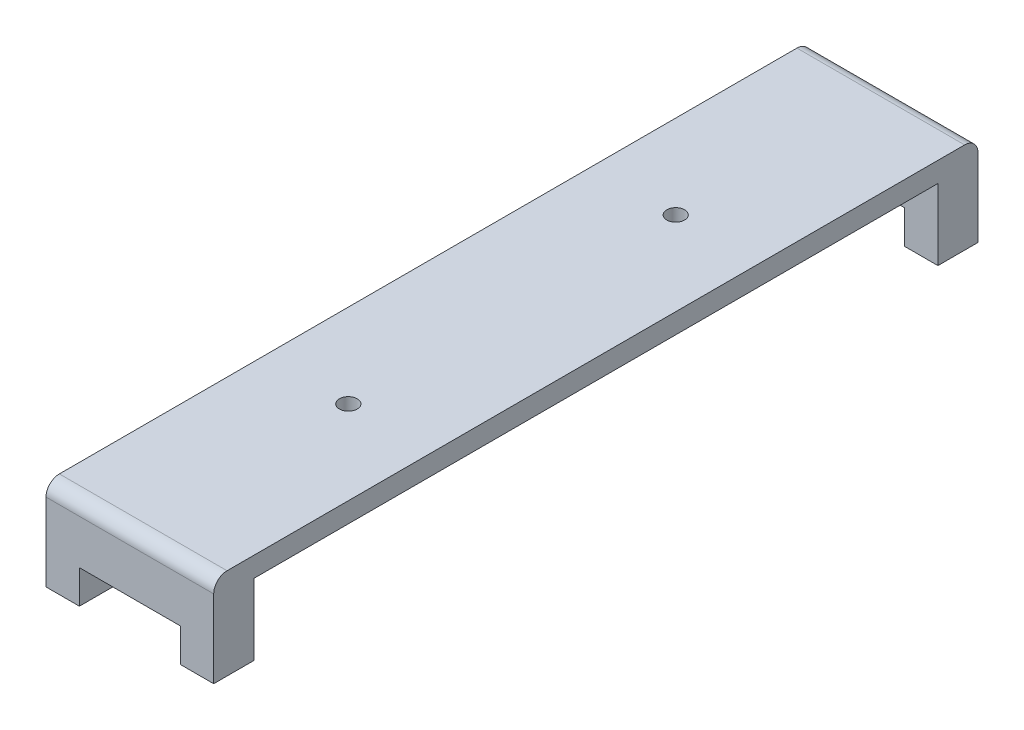
from build123d import *

# Parameters (mm, degrees)
SKETCH2_W           = 25.1
SKETCH2_H           = 57.2
SKETCH2_R           = 1.335
BOSS_EXTRUDE1_DEPTH = 3
BOSS_EXTRUDE2_DEPTH = 6
FILLET1_R           = 2


with BuildPart() as part:
    # Sketch2 → Boss-Extrude1 (new body)
    with BuildSketch(Plane(origin=(0, 0, 0), x_dir=(1, 0, 0), z_dir=(0, 1, 0))):
        with Locations((0, 28.6)):
            Rectangle(SKETCH2_W, SKETCH2_H)
        with Locations((0, 24.5)):
            Circle(SKETCH2_R, mode=Mode.SUBTRACT)
    boss_extrude1 = extrude(amount=BOSS_EXTRUDE1_DEPTH)

    # Sketch4 → Boss-Extrude2 (add)
    with BuildSketch(Plane(origin=(0, 0, -57.2), x_dir=(-1, 0, 0), z_dir=(0, 0, -1))):
        Polygon((12.55, 0), (-12.55, 0), (-12.55, -10.65), (-7.55, -10.65), (-7.55, -5.65), (7.55, -5.65), (7.55, -10.65), (12.55, -10.65), align=None)
    boss_extrude2 = extrude(amount=-BOSS_EXTRUDE2_DEPTH)

    # Mirror1: Boss-Extrude1, Boss-Extrude2 across plane
    add(boss_extrude1.mirror(Plane.XY))
    add(boss_extrude2.mirror(Plane.XY))

    # Fillet1
    fillet1_edges = [part.edges().sort_by_distance(p)[0] for p in [
        (0, 3, -57.2),
        (0, 3, 57.2),
    ]]
    fillet(fillet1_edges, radius=FILLET1_R)


solid = part.part
